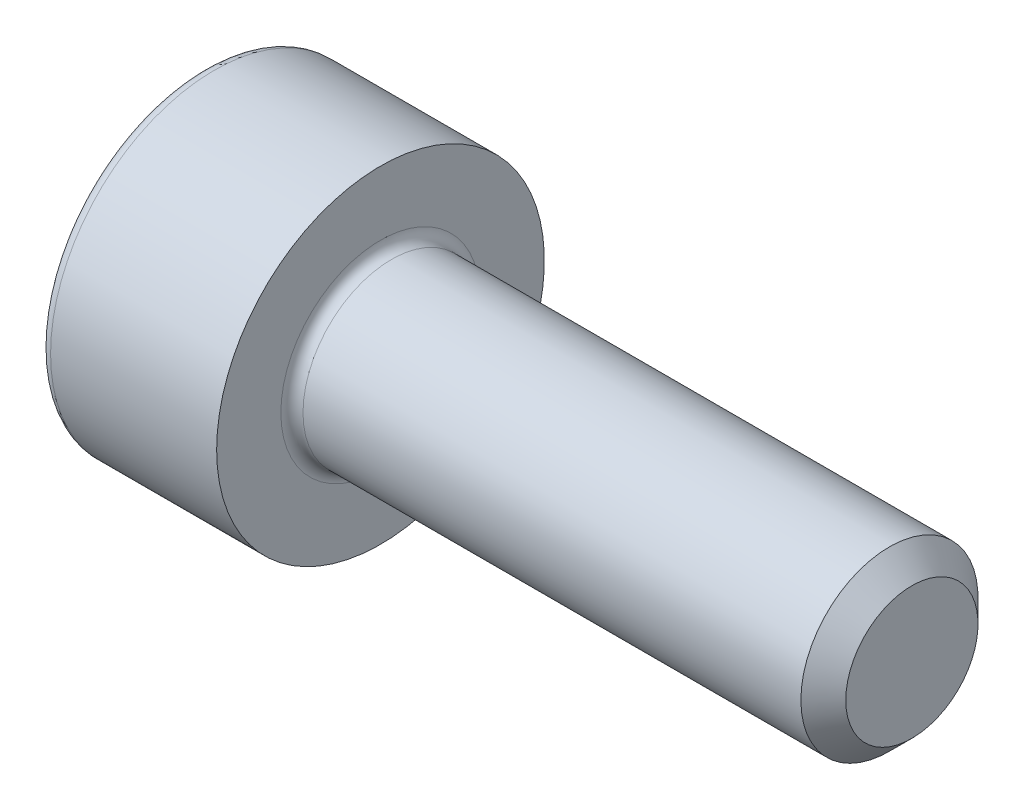
from build123d import *

# Parameters (mm, degrees)
CUT_EXTRUDE1_DEPTH = 1.1


with BuildPart() as part:
    # Sketch1 → Revolve1 (revolve)
    with BuildSketch(Plane.XY):
        with BuildLine():
            Line((5.7465, 1), (0.125, 1))
            ThreePointArc((0.125, 1), (0.036611652, 1.036611652), (0, 1.125))
            Line((0, 1.125), (0, 1.85))
            Line((0, 1.85), (-1.875, 1.85))
            ThreePointArc((-1.875, 1.85), (-1.963388348, 1.813388348), (-2, 1.725))
            Line((-2, 1.725), (-2, 0))
            Line((-2, 0), (6, 0))
            Line((6, 0), (6, 0.7465))
            Line((6, 0.7465), (5.7465, 1))
        make_face()
    revolve(axis=Axis((-2, 0, 0), (1, 0, 0)))

    # Sketch2 → Cut-Extrude1 (cut)
    with BuildSketch(Plane.ZY.offset(2)):
        Polygon((0.75, 0.433012702), (0, 0.866025404), (-0.75, 0.433012702), (-0.75, -0.433012702), (0, -0.866025404), (0.75, -0.433012702), align=None)
    extrude(amount=-CUT_EXTRUDE1_DEPTH, mode=Mode.SUBTRACT)


solid = part.part
